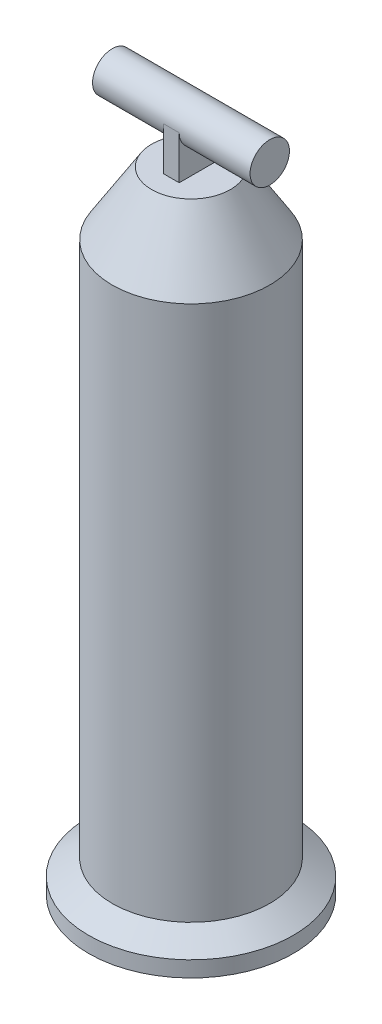
from build123d import *

# Parameters (mm, degrees)
SKETCH2_W                = 2
SKETCH2_H                = 5
BOSS_EXTRUDE1_DEPTH      = 8
CUT_EXTRUDE1_DEPTH       = 91.049986119
CUT_EXTRUDE1_DEPTH_BACK  = 91.049986119
BOSS_EXTRUDE2_DEPTH      = 9
BOSS_EXTRUDE2_DEPTH_BACK = 11


with BuildPart() as part:
    # Sketch1 → Revolve1 (revolve)
    with BuildSketch(Plane(origin=(0, 0, 0), x_dir=(0, 0, -1), z_dir=(1, 0, 0))):
        Polygon((-10, 4), (-10, 72), (-5, 80), (0, 80), (0, 71.426407547), (-8, 71.426407547), (-8, 0), (-13, 0), (-13, 2), align=None)
    revolve(axis=Axis((0, 80, 0), (0, -1, 0)))

    # Sketch2 → Boss-Extrude1 (add)
    with BuildSketch(Plane(origin=(0, 80, 0), x_dir=(1, 0, 0), z_dir=(0, 1, 0))):
        Rectangle(SKETCH2_W, SKETCH2_H)
    extrude(amount=BOSS_EXTRUDE1_DEPTH)

    # Sketch3 → Cut-Extrude1 (cut, two sides: drawn at the far end of the back side and taken through both)
    with BuildSketch(Plane.ZY.offset(1).offset(-CUT_EXTRUDE1_DEPTH_BACK)):
        with BuildLine():
            ThreePointArc((-2.5, 85.5), (0, 88), (2.5, 85.5))
            Line((2.5, 85.5), (2.5, 90.5))
            Line((2.5, 90.5), (-2.5, 90.5))
            Line((-2.5, 90.5), (-2.5, 85.5))
        make_face()
    extrude(amount=CUT_EXTRUDE1_DEPTH + CUT_EXTRUDE1_DEPTH_BACK, mode=Mode.SUBTRACT)

    # Sketch3_3 → Boss-Extrude2 (add, two sides: drawn at the far end of the back side and taken through both)
    with BuildSketch(Plane.ZY.offset(1).offset(-BOSS_EXTRUDE2_DEPTH_BACK)):
        with BuildLine():
            ThreePointArc((2.5, 85.5), (0, 88), (-2.5, 85.5))
            ThreePointArc((-2.5, 85.5), (0, 83), (2.5, 85.5))
        make_face()
    extrude(amount=BOSS_EXTRUDE2_DEPTH + BOSS_EXTRUDE2_DEPTH_BACK)


solid = part.part
